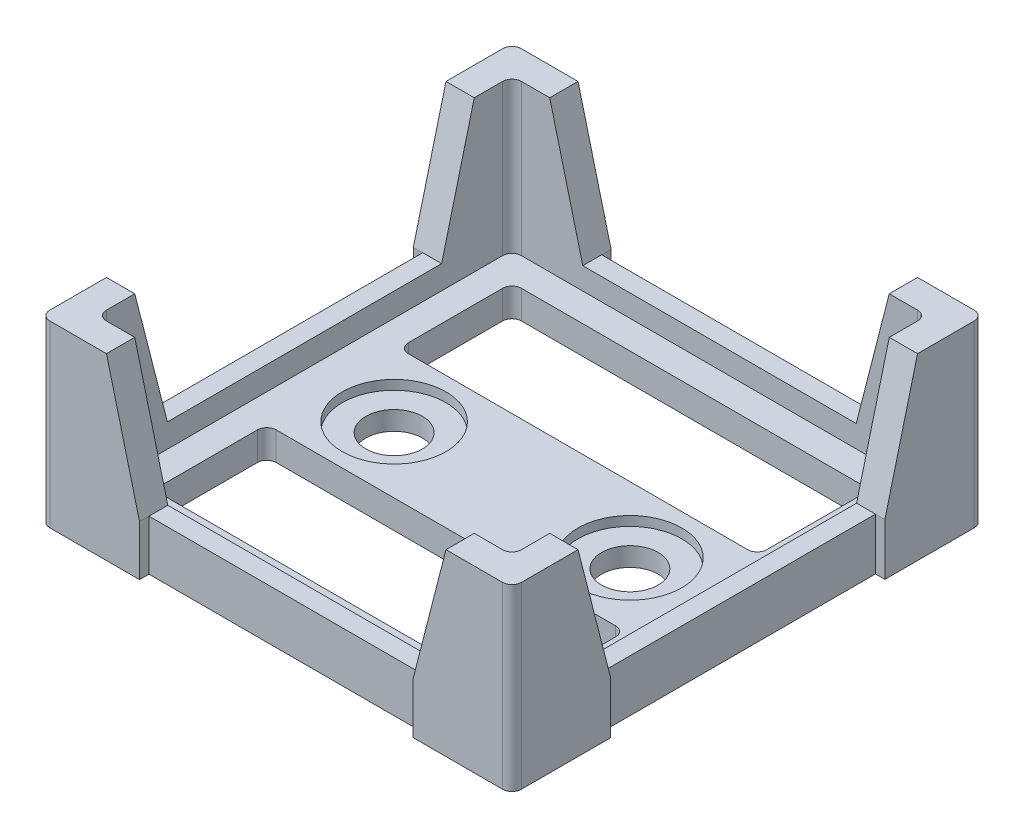
from build123d import *

# Parameters (mm, degrees)
SKETCH1_W                      = 50
SKETCH1_H                      = 50
BOSS_EXTRUDE1_DEPTH            = 19
SKETCH2_W                      = 44
SKETCH2_H                      = 44
CUT_EXTRUDE1_DEPTH             = 16
CBORE_FOR_M6_SHCS1_D           = 6
CBORE_FOR_M6_SHCS1_CBORE_D     = 11
CBORE_FOR_M6_SHCS1_CBORE_DEPTH = 1
SKETCH6_W                      = 38
SKETCH6_H                      = 12
CUT_EXTRUDE2_DEPTH             = 16
FILLET1_R                      = 1
FILLET3_R                      = 1
CUT_EXTRUDE3_DEPTH             = 51
CUT_EXTRUDE4_DEPTH             = 51
SKETCH9_W                      = 1
SKETCH9_H                      = 29.077623466
CUT_EXTRUDE5_DEPTH             = 10
SKETCH10_W                     = 28.99096046
SKETCH10_H                     = 1
CUT_EXTRUDE6_DEPTH             = 10
SKETCH11_W                     = 28.99096046
SKETCH11_H                     = 1
CUT_EXTRUDE7_DEPTH             = 10
SKETCH12_W                     = 1
SKETCH12_H                     = 29.077623466
CUT_EXTRUDE8_DEPTH             = 10


with BuildPart() as part:
    # Sketch1 → Boss-Extrude1 (new body)
    with BuildSketch(Plane(origin=(0, 0, 0), x_dir=(1, 0, 0), z_dir=(0, 1, 0))):
        Rectangle(SKETCH1_W, SKETCH1_H)
    extrude(amount=BOSS_EXTRUDE1_DEPTH)

    # Sketch2 → Cut-Extrude1 (cut)
    with BuildSketch(Plane(origin=(0, 19, 0), x_dir=(1, 0, 0), z_dir=(0, 1, 0))):
        Rectangle(SKETCH2_W, SKETCH2_H)
    extrude(amount=-CUT_EXTRUDE1_DEPTH, mode=Mode.SUBTRACT)

    # CBORE for M6 SHCS1 (through all)
    with Locations(Plane(origin=(-12.5, 3, 0), x_dir=(0, 0, 1), z_dir=(0, 1, 0))):
        with Locations((0, 0), (0, 25)):
            CounterBoreHole(CBORE_FOR_M6_SHCS1_D / 2, CBORE_FOR_M6_SHCS1_CBORE_D / 2, CBORE_FOR_M6_SHCS1_CBORE_DEPTH)

    # Sketch6 → Cut-Extrude2 (cut)
    with BuildSketch(Plane(origin=(0, 3, 0), x_dir=(1, 0, 0), z_dir=(0, 1, 0))):
        with Locations((0, -13)):
            Rectangle(SKETCH6_W, SKETCH6_H)
        with Locations((0, 13)):
            Rectangle(SKETCH6_W, SKETCH6_H)
    extrude(amount=-CUT_EXTRUDE2_DEPTH, mode=Mode.SUBTRACT)

    # Fillet1
    fillet1_edges = [part.edges().sort_by_distance(p)[0] for p in [
        (-22, 11, 22),
        (-22, 11, -22),
        (22, 11, -22),
        (22, 11, 22),
        (-19, 1.5, 19),
        (-19, 1.5, 7),
        (19, 1.5, 7),
        (19, 1.5, 19),
        (-19, 1.5, -7),
        (-19, 1.5, -19),
        (19, 1.5, -19),
        (19, 1.5, -7),
    ]]
    fillet(fillet1_edges, radius=FILLET1_R)

    # Fillet3
    fillet3_edges = [part.edges().sort_by_distance(p)[0] for p in [
        (-25, 9.5, -25),
        (25, 9.5, -25),
        (25, 9.5, 25),
        (-25, 9.5, 25),
    ]]
    fillet(fillet3_edges, radius=FILLET3_R)

    # Sketch7 → Cut-Extrude3 (cut, through all)
    with BuildSketch(Plane(origin=(25, 0, 0), x_dir=(0, 0, -1), z_dir=(1, 0, 0))):
        Polygon((14.538811733, 5.5), (-14.538811733, 5.5), (-18, 19), (18, 19), align=None)
    extrude(amount=-CUT_EXTRUDE3_DEPTH, mode=Mode.SUBTRACT)

    # Sketch8 → Cut-Extrude4 (cut, through all)
    with BuildSketch(Plane.XY.offset(25)):
        Polygon((-18, 19), (18, 19), (14.49548023, 5.330990042), (-14.49548023, 5.330990042), align=None)
    extrude(amount=-CUT_EXTRUDE4_DEPTH, mode=Mode.SUBTRACT)

    # Sketch9 → Cut-Extrude5 (cut)
    with BuildSketch(Plane(origin=(0, 5.5, 0), x_dir=(1, 0, 0), z_dir=(0, 1, 0))):
        with Locations((24.5, 0)):
            Rectangle(SKETCH9_W, SKETCH9_H)
    extrude(amount=-CUT_EXTRUDE5_DEPTH, mode=Mode.SUBTRACT)

    # Sketch10 → Cut-Extrude6 (cut)
    with BuildSketch(Plane(origin=(0, 5.330990042, 0), x_dir=(1, 0, 0), z_dir=(0, 1, 0))):
        with Locations((0, -24.5)):
            Rectangle(SKETCH10_W, SKETCH10_H)
    extrude(amount=-CUT_EXTRUDE6_DEPTH, mode=Mode.SUBTRACT)

    # Sketch11 → Cut-Extrude7 (cut)
    with BuildSketch(Plane(origin=(0, 5.330990042, 0), x_dir=(1, 0, 0), z_dir=(0, 1, 0))):
        with Locations((0, 24.5)):
            Rectangle(SKETCH11_W, SKETCH11_H)
    extrude(amount=-CUT_EXTRUDE7_DEPTH, mode=Mode.SUBTRACT)

    # Sketch12 → Cut-Extrude8 (cut)
    with BuildSketch(Plane(origin=(0, 5.5, 0), x_dir=(1, 0, 0), z_dir=(0, 1, 0))):
        with Locations((-24.5, 0)):
            Rectangle(SKETCH12_W, SKETCH12_H)
    extrude(amount=-CUT_EXTRUDE8_DEPTH, mode=Mode.SUBTRACT)


solid = part.part
